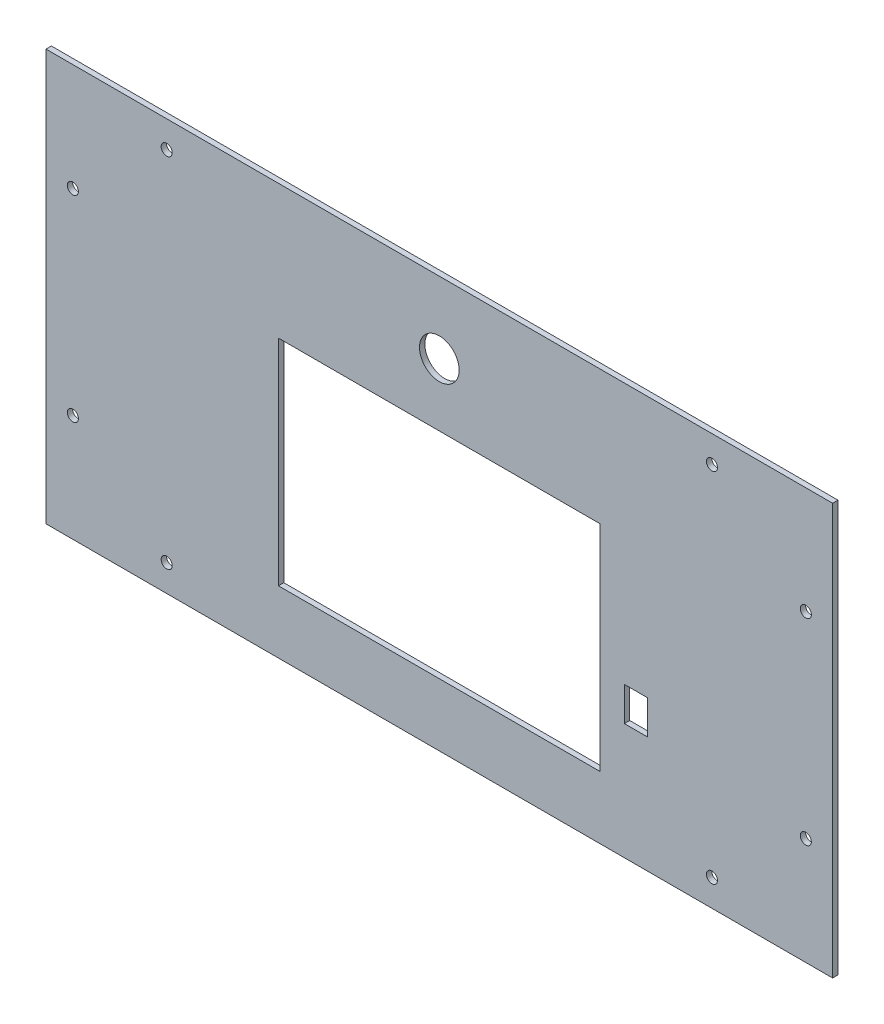
from build123d import *

# Parameters (mm, degrees)
CROQUIS1_W              = 440
CROQUIS1_H              = 230
SALIENTE_EXTRUIR1_DEPTH = 3
CROQUIS2_R              = 3.1
CORTAR_EXTRUIR1_DEPTH   = 4
CROQUIS3_W              = 180
CROQUIS3_H              = 120
CORTAR_EXTRUIR2_DEPTH   = 4
CROQUIS4_R              = 11.1
CORTAR_EXTRUIR3_DEPTH   = 4
CROQUIS5_W              = 13
CROQUIS5_H              = 19
CORTAR_EXTRUIR4_DEPTH   = 4


with BuildPart() as part:
    # Croquis1 → Saliente-Extruir1 (new body)
    with BuildSketch(Plane.XY):
        Rectangle(CROQUIS1_W, CROQUIS1_H)
    extrude(amount=SALIENTE_EXTRUIR1_DEPTH)

    # Croquis2 → Cortar-Extruir1 (cut, through all)
    with BuildSketch(Plane.XY.offset(3)):
        with Locations((-205, 55)):
            Circle(CROQUIS2_R)
        with Locations((-152.5, 100)):
            Circle(CROQUIS2_R)
        with Locations((152.5, 100)):
            Circle(CROQUIS2_R)
        with Locations((-205, -55)):
            Circle(CROQUIS2_R)
        with Locations((205, -55)):
            Circle(CROQUIS2_R)
        with Locations((205, 55)):
            Circle(CROQUIS2_R)
        with Locations((152.5, -100)):
            Circle(CROQUIS2_R)
        with Locations((-152.5, -100)):
            Circle(CROQUIS2_R)
    extrude(amount=-CORTAR_EXTRUIR1_DEPTH, mode=Mode.SUBTRACT)

    # Croquis3 → Cortar-Extruir2 (cut, through all)
    with BuildSketch(Plane(origin=(0, 0, 0), x_dir=(-1, 0, 0), z_dir=(0, 0, -1))):
        with Locations((0, -20)):
            Rectangle(CROQUIS3_W, CROQUIS3_H)
    extrude(amount=-CORTAR_EXTRUIR2_DEPTH, mode=Mode.SUBTRACT)

    # Croquis4 → Cortar-Extruir3 (cut, through all)
    with BuildSketch(Plane(origin=(0, 0, 0), x_dir=(-1, 0, 0), z_dir=(0, 0, -1))):
        with Locations((0, 75)):
            Circle(CROQUIS4_R)
    extrude(amount=-CORTAR_EXTRUIR3_DEPTH, mode=Mode.SUBTRACT)

    # Croquis5 → Cortar-Extruir4 (cut, through all)
    with BuildSketch(Plane(origin=(0, 0, 0), x_dir=(-1, 0, 0), z_dir=(0, 0, -1))):
        with Locations((-110, -40.5)):
            Rectangle(CROQUIS5_W, CROQUIS5_H)
    extrude(amount=-CORTAR_EXTRUIR4_DEPTH, mode=Mode.SUBTRACT)


solid = part.part
